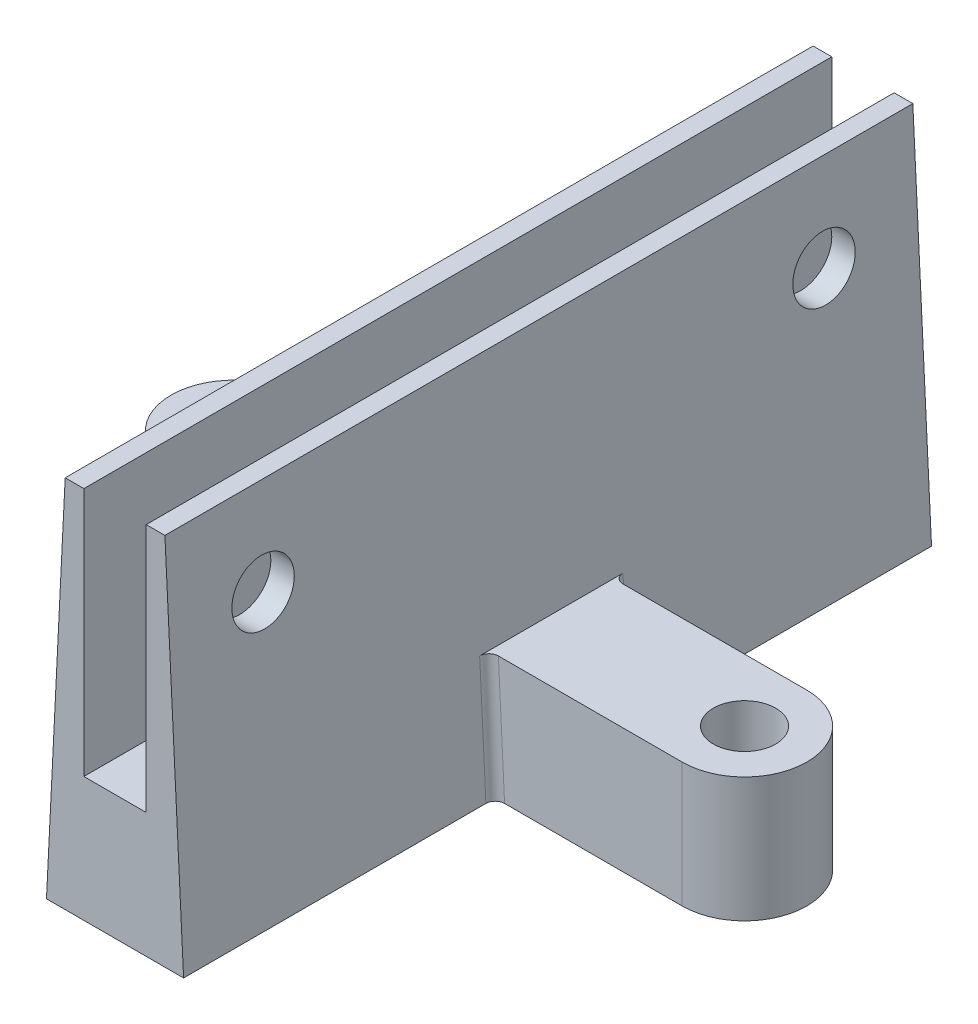
from build123d import *

# Parameters (mm, degrees)
BOSS_EXTRUDE1_DEPTH      = 120
SKETCH10_W               = 20
SKETCH10_H               = 20
BOSS_EXTRUDE6_DEPTH      = 4
BOSS_EXTRUDE6_DEPTH_BACK = 30
SKETCH13_W               = 20
SKETCH13_H               = 20
BOSS_EXTRUDE8_DEPTH      = 30
BOSS_EXTRUDE8_DEPTH_BACK = 5
BOSS_EXTRUDE9_DEPTH      = 20
SKETCH15_R               = 5
CUT_EXTRUDE5_DEPTH       = 20
FILLET2_R                = 1.5
SKETCH16_R               = 5
CUT_EXTRUDE6_DEPTH       = 20
CUT_EXTRUDE6_DEPTH_BACK  = 20


with BuildPart() as part:
    # Sketch1 → Boss-Extrude1 (new body)
    with BuildSketch(Plane.XY):
        Polygon((0, 0), (22, 0), (19, 60), (16, 60), (16, 20), (6, 20), (6, 60), (3, 60), align=None)
    extrude(amount=BOSS_EXTRUDE1_DEPTH)

    # Sketch10 → Boss-Extrude6 (add, two sides)
    with BuildSketch(Plane(origin=(0, 0, 0), x_dir=(0, 0, -1), z_dir=(1, 0, 0))) as boss_extrude6_sk:
        with Locations((-60, 10)):
            Rectangle(SKETCH10_W, SKETCH10_H)
    extrude(amount=BOSS_EXTRUDE6_DEPTH)
    extrude(boss_extrude6_sk.sketch, amount=-BOSS_EXTRUDE6_DEPTH_BACK)

    # Sketch13 → Boss-Extrude8 (add, two sides)
    with BuildSketch(Plane(origin=(22, 0, 0), x_dir=(0, 0, -1), z_dir=(1, 0, 0))) as boss_extrude8_sk:
        with Locations((-60, 10)):
            Rectangle(SKETCH13_W, SKETCH13_H)
    extrude(amount=BOSS_EXTRUDE8_DEPTH)
    extrude(boss_extrude8_sk.sketch, amount=-BOSS_EXTRUDE8_DEPTH_BACK)

    # Sketch14 → Boss-Extrude9 (add)
    with BuildSketch(Plane.XZ):
        with BuildLine():
            Line((-30, 70), (-30, 50))
            ThreePointArc((-30, 50), (-40, 60), (-30, 70))
        make_face()
        with BuildLine():
            Line((52, 70), (52, 50))
            ThreePointArc((52, 50), (62, 60), (52, 70))
        make_face()
    extrude(amount=-BOSS_EXTRUDE9_DEPTH)

    # Sketch15 → Cut-Extrude5 (cut)
    with BuildSketch(Plane.XZ):
        with Locations((-30, 60)):
            Circle(SKETCH15_R)
        with Locations((52, 60)):
            Circle(SKETCH15_R)
    extrude(amount=-CUT_EXTRUDE5_DEPTH, mode=Mode.SUBTRACT)

    # Fillet2
    fillet2_edges = [part.edges().sort_by_distance(p)[0] for p in [
        (0.5, 10, 70),
        (0.5, 10, 50),
        (21.5, 10, 70),
        (21.5, 10, 50),
    ]]
    fillet(fillet2_edges, radius=FILLET2_R)

    # Sketch16 → Cut-Extrude6 (cut, two sides)
    with BuildSketch(Plane(origin=(6, 0, 0), x_dir=(0, 0, -1), z_dir=(1, 0, 0))) as cut_extrude6_sk:
        with Locations((-105, 45)):
            Circle(SKETCH16_R)
        with Locations((-15, 45)):
            Circle(SKETCH16_R)
    extrude(amount=CUT_EXTRUDE6_DEPTH, mode=Mode.SUBTRACT)
    extrude(cut_extrude6_sk.sketch, amount=-CUT_EXTRUDE6_DEPTH_BACK, mode=Mode.SUBTRACT)


solid = part.part
